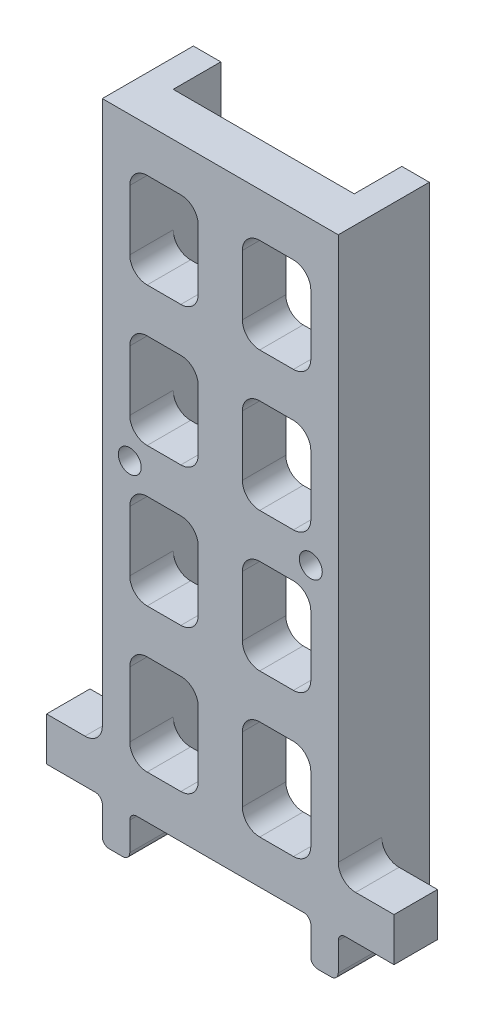
from build123d import *

# Parameters (mm, degrees)
SKETCH1_W                      = 3.95
SKETCH1_H                      = 13.1
BOSS_EXTRUDE1_DEPTH            = 93
SKETCH2_W                      = 3.95
SKETCH2_H                      = 13.1
BOSS_EXTRUDE2_DEPTH            = 93
SKETCH3_W                      = 6.25
SKETCH3_H                      = 6.35
BOSS_EXTRUDE3_DEPTH            = 30
LPATTERN1_COUNT                = 4
LPATTERN1_PITCH                = 20
SKETCH4_W                      = 6.35
SKETCH4_H                      = 6.25
BOSS_EXTRUDE4_DEPTH            = 60
FILLET1_R                      = 2.5
SKETCH5_W                      = 6.25
SKETCH5_H                      = 6.25
BOSS_EXTRUDE5_DEPTH            = 25
FILLET2_R                      = 2.5
FILLET3_R                      = 2.5
SKETCH6_W                      = 6.35
SKETCH6_H                      = 6.25
BOSS_EXTRUDE6_DEPTH            = 14.35
FILLET4_R                      = 2.5
F_3_3_3_3_DIAMETER_HOLE1_D     = 3.3
F_3_3_3_3_DIAMETER_HOLE1_DEPTH = 5
F_3_3_3_3_DIAMETER_HOLE1_TIP   = 0.991420021
FILLET5_R                      = 1
FILLET6_R                      = 1


with BuildPart() as part:
    # Sketch1 → Boss-Extrude1 (new body)
    with BuildSketch(Plane(origin=(0, 0, 0), x_dir=(1, 0, 0), z_dir=(0, 1, 0))):
        with Locations((0, 6.55)):
            Rectangle(SKETCH1_W, SKETCH1_H)
    extrude(amount=BOSS_EXTRUDE1_DEPTH)



with BuildPart() as body_2:
    # Sketch2 → Boss-Extrude2 (new body)
    with BuildSketch(Plane(origin=(0, 0, 0), x_dir=(1, 0, 0), z_dir=(0, 1, 0))):
        with Locations((30, 6.55)):
            Rectangle(SKETCH2_W, SKETCH2_H)
    extrude(amount=BOSS_EXTRUDE2_DEPTH)


with BuildPart() as part_1:
    add(part.part)

    add(body_2.part)  # Boss-Extrude3 merges body 2
    # Sketch3 → Boss-Extrude3 (add)
    with BuildSketch(Plane(origin=(1.975, 0, 0), x_dir=(0, 0, -1), z_dir=(1, 0, 0))):
        with Locations((3.125, 89.825)):
            Rectangle(SKETCH3_W, SKETCH3_H)
    boss_extrude3 = extrude(amount=BOSS_EXTRUDE3_DEPTH)

    # LPattern1: Boss-Extrude3 ×4
    with Locations(*[(0, -i * LPATTERN1_PITCH, 0) for i in range(1, LPATTERN1_COUNT)]):
        add(boss_extrude3)

    # Sketch4 → Boss-Extrude4 (add)
    with BuildSketch(Plane.XZ.offset(-86.65)):
        with Locations((15, -3.125)):
            Rectangle(SKETCH4_W, SKETCH4_H)
    extrude(amount=BOSS_EXTRUDE4_DEPTH)

    # Fillet1
    fillet1_edges = [part_1.edges().sort_by_distance(p)[0] for p in [
        (18.175, 66.65, -3.125),
        (18.175, 53, -3.125),
        (18.175, 73, -3.125),
        (18.175, 86.65, -3.125),
        (18.175, 46.65, -3.125),
        (11.825, 66.65, -3.125),
        (11.825, 53, -3.125),
        (11.825, 73, -3.125),
        (11.825, 86.65, -3.125),
        (11.825, 46.65, -3.125),
        (28.025, 86.65, -3.125),
        (1.975, 86.65, -3.125),
        (28.025, 66.65, -3.125),
        (28.025, 73, -3.125),
        (1.975, 66.65, -3.125),
        (1.975, 73, -3.125),
        (28.025, 46.65, -3.125),
        (28.025, 53, -3.125),
        (1.975, 46.65, -3.125),
        (1.975, 53, -3.125),
        (28.025, 33, -3.125),
        (1.975, 33, -3.125),
        (11.825, 33, -3.125),
        (18.175, 33, -3.125),
    ]]
    fillet(fillet1_edges, radius=FILLET1_R)

    # Sketch5 → Boss-Extrude5 (add, symmetric)
    with BuildSketch(Plane.ZY.offset(-15)):
        with Locations((-3.125, 9.175)):
            Rectangle(SKETCH5_W, SKETCH5_H)
    extrude(amount=BOSS_EXTRUDE5_DEPTH, both=True)

    # Fillet2
    fillet2_edges = [part_1.edges().sort_by_distance(p)[0] for p in [
        (1.975, 12.3, -3.125),
        (28.025, 12.3, -3.125),
        (28.025, 26.65, -3.125),
        (1.975, 26.65, -3.125),
    ]]
    fillet(fillet2_edges, radius=FILLET2_R)

    # Fillet3
    fillet3_edges = [part_1.edges().sort_by_distance(p)[0] for p in [
        (31.975, 12.3, -3.125),
        (-1.975, 12.3, -3.125),
    ]]
    fillet(fillet3_edges, radius=FILLET3_R)

    # Sketch6 → Boss-Extrude6 (add)
    with BuildSketch(Plane.XZ.offset(-26.65)):
        with Locations((15, -3.125)):
            Rectangle(SKETCH6_W, SKETCH6_H)
    extrude(amount=BOSS_EXTRUDE6_DEPTH)

    # Fillet4
    fillet4_edges = [part_1.edges().sort_by_distance(p)[0] for p in [
        (18.175, 26.65, -3.125),
        (11.825, 26.65, -3.125),
        (18.175, 12.3, -3.125),
        (11.825, 12.3, -3.125),
    ]]
    fillet(fillet4_edges, radius=FILLET4_R)

    # Ø3.3 (3.3) Diameter Hole1
    with Locations(Plane.XY):
        with Locations((28.025, 49.825), (1.975, 49.825)):
            Hole(F_3_3_3_3_DIAMETER_HOLE1_D / 2, depth=F_3_3_3_3_DIAMETER_HOLE1_DEPTH)
            with Locations((0, 0, -(F_3_3_3_3_DIAMETER_HOLE1_DEPTH + F_3_3_3_3_DIAMETER_HOLE1_TIP / 2))):  # 118° drill point
                Cone(0, F_3_3_3_3_DIAMETER_HOLE1_D / 2, F_3_3_3_3_DIAMETER_HOLE1_TIP, mode=Mode.SUBTRACT)

    # Fillet5
    fillet5_edges = [part_1.edges().sort_by_distance(p)[0] for p in [
        (28.025, 0, -6.55),
        (31.975, 0, -6.55),
        (1.975, 0, -6.55),
        (-1.975, 0, -6.55),
    ]]
    fillet(fillet5_edges, radius=FILLET5_R)

    # Fillet6
    fillet6_edges = [part_1.edges().sort_by_distance(p)[0] for p in [
        (31.975, 6.05, -3.125),
        (1.975, 6.05, -3.125),
        (28.025, 6.05, -3.125),
        (-1.975, 6.05, -3.125),
    ]]
    fillet(fillet6_edges, radius=FILLET6_R)


solid = part_1.part
